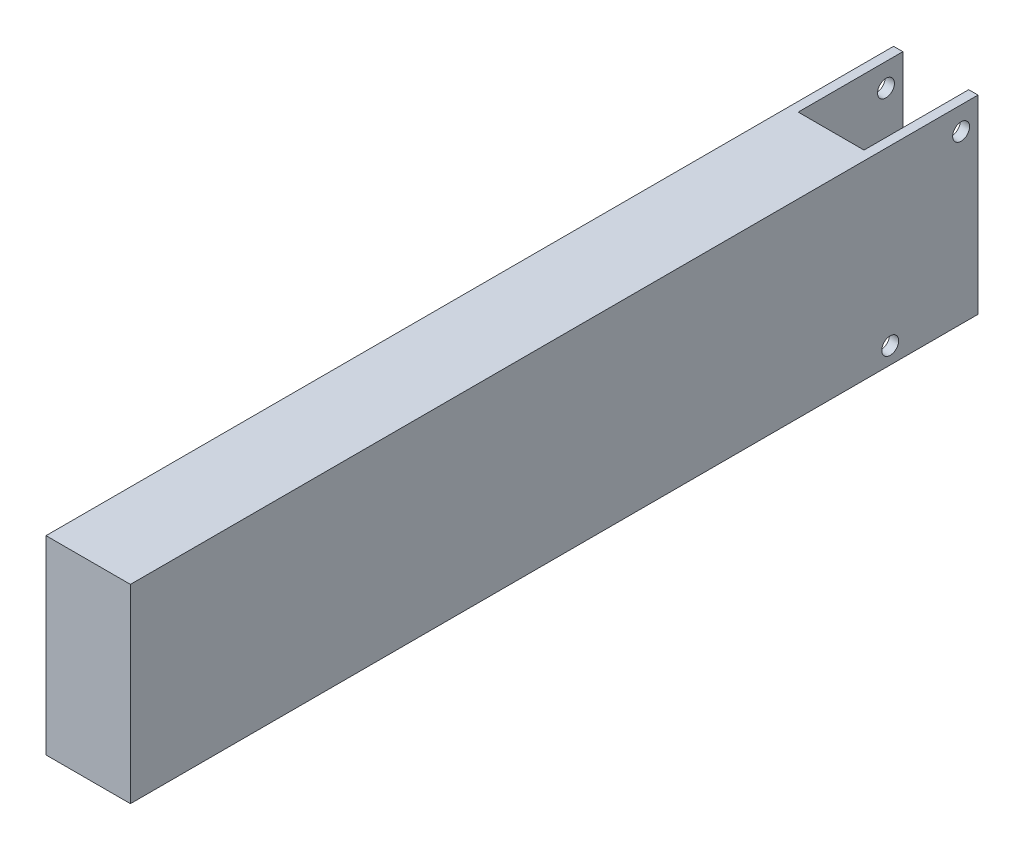
from build123d import *

# Parameters (mm, degrees)
SKETCH1_W               = 12.7
SKETCH1_H               = 28.575
BOSS_EXTRUDE1_DEPTH     = 111.76
SKETCH3_W               = 1.397
SKETCH3_H               = 28.575
BOSS_EXTRUDE3_DEPTH     = 15.748
SKETCH7_R               = 1.27
CUT_EXTRUDE3_DEPTH      = 1
CUT_EXTRUDE3_DEPTH_BACK = 13.7


with BuildPart() as part:
    # Sketch1 → Boss-Extrude1 (new body)
    with BuildSketch(Plane.XY):
        with Locations((6.35, 14.2875)):
            Rectangle(SKETCH1_W, SKETCH1_H)
    extrude(amount=BOSS_EXTRUDE1_DEPTH)

    # Sketch3 → Boss-Extrude3 (add)
    with BuildSketch(Plane(origin=(0, 0, 0), x_dir=(-1, 0, 0), z_dir=(0, 0, -1))):
        with Locations((-0.6985, 14.2875)):
            Rectangle(SKETCH3_W, SKETCH3_H)
        with Locations((-12.0015, 14.2875)):
            Rectangle(SKETCH3_W, SKETCH3_H)
    extrude(amount=BOSS_EXTRUDE3_DEPTH)

    # Sketch7 → Cut-Extrude3 (cut, two sides)
    with BuildSketch(Plane.ZY) as cut_extrude3_sk:
        with Locations((-13.208, 25.0952)):
            Circle(SKETCH7_R)
        with Locations((-2.54, 2.54)):
            Circle(SKETCH7_R)
    extrude(amount=CUT_EXTRUDE3_DEPTH, mode=Mode.SUBTRACT)
    extrude(cut_extrude3_sk.sketch, amount=-CUT_EXTRUDE3_DEPTH_BACK, mode=Mode.SUBTRACT)


solid = part.part
